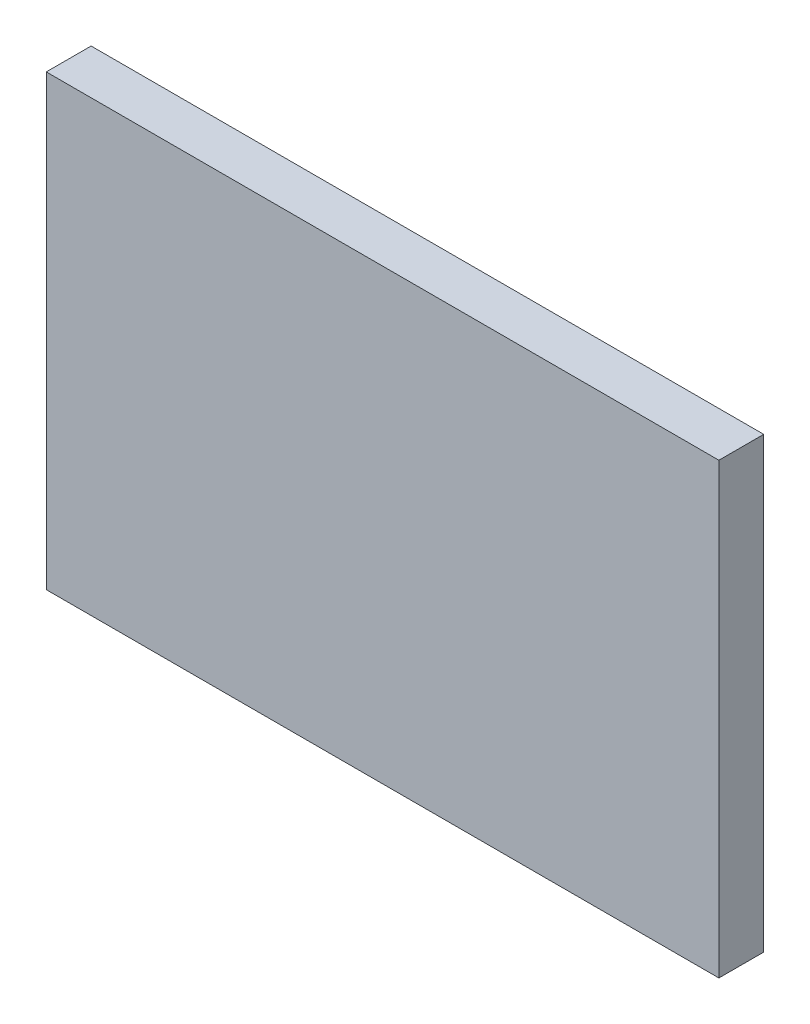
from build123d import *

# Parameters (mm, degrees)
ESBO_O1_W                = 300
ESBO_O1_H                = 200
RESSALTO_EXTRUS_O1_DEPTH = 20


with BuildPart() as part:
    # Esboço1 → Ressalto-extrusão1 (new body)
    with BuildSketch(Plane.XY):
        with Locations((-1.757177922, 51.133144476)):
            Rectangle(ESBO_O1_W, ESBO_O1_H)
    extrude(amount=RESSALTO_EXTRUS_O1_DEPTH)


solid = part.part
